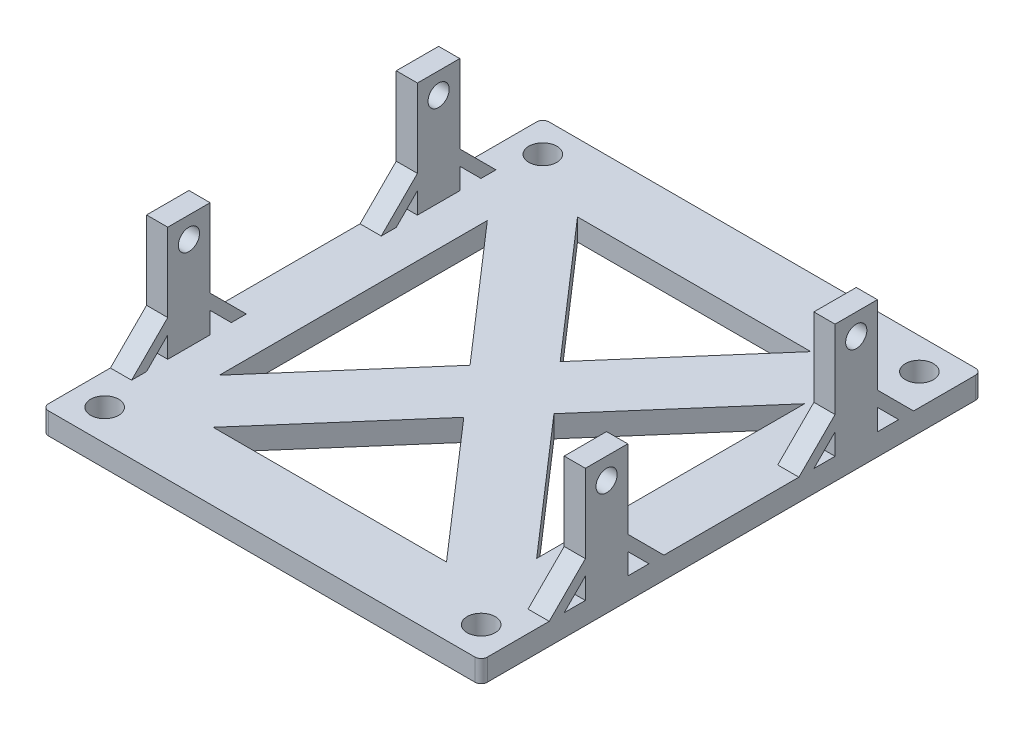
from build123d import *

# Parameters (mm, degrees)
SKETCH1_W                                  = 70.427
SKETCH1_H                                  = 60.325
BOSS_EXTRUDE1_DEPTH                        = 3.5
SKETCH4_R                                  = 1.7
BOSS_EXTRUDE2_DEPTH                        = 3.4
MIRROR1_AT_THE_SECOND_PLANE_COPY_1_SKETC_R = 1.7
MIRROR1_AT_THE_SECOND_PLANE_COPY_1_DEPTH   = 3.4
SKETCH6_W                                  = 70.427
SKETCH6_H                                  = 10
SKETCH6_R                                  = 2.25
BOSS_EXTRUDE3_DEPTH                        = 3.5
FILLET1_R                                  = 1
CUT_EXTRUDE3_DEPTH                         = 19.368750112
CUT_EXTRUDE3_DEPTH_BACK                    = 4.5


with BuildPart() as part:
    # Sketch1 → Boss-Extrude1 (new body)
    with BuildSketch(Plane(origin=(0, 0, 0), x_dir=(1, 0, 0), z_dir=(0, 1, 0))):
        Rectangle(SKETCH1_W, SKETCH1_H)
    extrude(amount=BOSS_EXTRUDE1_DEPTH)

    # Sketch4 → Boss-Extrude2 (add)
    with BuildSketch(Plane.ZY.offset(35.2135)):
        Polygon((-29.239788056, 3.5), (-23.435625, 9.304163056), (-23.435625, 21.868750112), (-16.635625, 21.868750112), (-16.635625, 9.304163056), (-10.831461944, 3.5), (-13.235625, 3.5), (-16.635625, 6.9), (-16.635625, 3.5), (-23.435625, 3.5), (-23.435625, 6.9), (-26.835625, 3.5), align=None)
        with Locations((-20.035625, 18.468750112)):
            Circle(SKETCH4_R, mode=Mode.SUBTRACT)
    boss_extrude2 = extrude(amount=-BOSS_EXTRUDE2_DEPTH)

    # Mirror1: Boss-Extrude2 across plane
    add(boss_extrude2.mirror(Plane(origin=(0, 0, 0), x_dir=(0, 0, 1), z_dir=(1, 0, 0))))

    # Mirror1 at the second plane: Boss-Extrude2 across plane
    add(boss_extrude2.mirror(Plane(origin=(0, 0, 0), x_dir=(1, 0, 0), z_dir=(0, 0, -1))))

    # Mirror1 at the second plane copy 1 sketc → Mirror1 at the second plane copy 1 (add)
    with BuildSketch(Plane(origin=(35.2135, 0, 0), x_dir=(0, 0, -1), z_dir=(1, 0, 0))):
        Polygon((-29.239788056, 3.5), (-23.435625, 9.304163056), (-23.435625, 21.868750112), (-16.635625, 21.868750112), (-16.635625, 9.304163056), (-10.831461944, 3.5), (-13.235625, 3.5), (-16.635625, 6.9), (-16.635625, 3.5), (-23.435625, 3.5), (-23.435625, 6.9), (-26.835625, 3.5), align=None)
        with Locations((-20.035625, 18.468750112)):
            Circle(MIRROR1_AT_THE_SECOND_PLANE_COPY_1_SKETC_R, mode=Mode.SUBTRACT)
    extrude(amount=-MIRROR1_AT_THE_SECOND_PLANE_COPY_1_DEPTH)

    # Sketch6 → Boss-Extrude3 (add)
    with BuildSketch(Plane(origin=(0, 3.5, 0), x_dir=(1, 0, 0), z_dir=(0, 1, 0))):
        with Locations((0, 35.1625)):
            Rectangle(SKETCH6_W, SKETCH6_H)
        with Locations((-30.2135, 35.1625)):
            Circle(SKETCH6_R, mode=Mode.SUBTRACT)
        with Locations((30.2135, 35.1625)):
            Circle(SKETCH6_R, mode=Mode.SUBTRACT)
    boss_extrude3 = extrude(amount=-BOSS_EXTRUDE3_DEPTH)

    # Mirror2: Boss-Extrude3 across plane
    add(boss_extrude3.mirror(Plane.XY))

    # Fillet1
    fillet1_edges = [part.edges().sort_by_distance(p)[0] for p in [
        (-35.2135, 1.75, -40.1625),
        (35.2135, 1.75, -40.1625),
        (-35.2135, 1.75, 40.1625),
        (35.2135, 1.75, 40.1625),
    ]]
    fillet(fillet1_edges, radius=FILLET1_R)

    # Sketch7 → Cut-Extrude3 (cut, two sides)
    with BuildSketch(Plane(origin=(0, 3.5, 0), x_dir=(1, 0, 0), z_dir=(0, 1, 0))) as cut_extrude3_sk:
        Polygon((0, 7.735286309), (18.727217831, 29.239788056), (-18.727217831, 29.239788056), align=None)
        Polygon((25.4635, -21.504501748), (25.4635, 21.504501748), (6.736282169, 0), align=None)
        Polygon((-18.727217831, -29.239788056), (18.727217831, -29.239788056), (0, -7.735286309), align=None)
        Polygon((-6.736282169, 0), (-25.4635, 21.504501748), (-25.4635, -21.504501748), align=None)
    extrude(amount=CUT_EXTRUDE3_DEPTH, mode=Mode.SUBTRACT)
    extrude(cut_extrude3_sk.sketch, amount=-CUT_EXTRUDE3_DEPTH_BACK, mode=Mode.SUBTRACT)


solid = part.part
